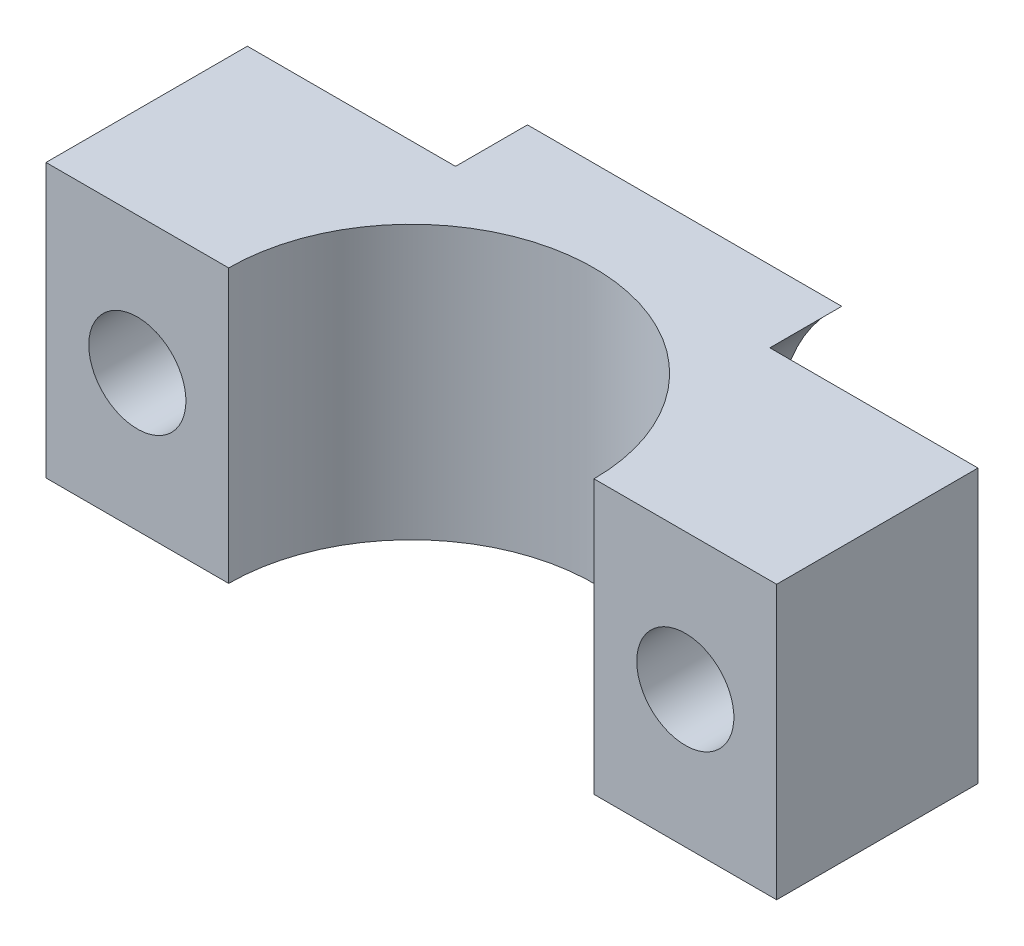
from build123d import *

# Parameters (mm, degrees)
BOSS_EXTRUDE1_DEPTH                           = 19
CBORE_FOR_M12_HEX_HEAD_CAP_SCREW2_D           = 6.75
CBORE_FOR_M12_HEX_HEAD_CAP_SCREW2_CBORE_D     = 25
CBORE_FOR_M12_HEX_HEAD_CAP_SCREW2_CBORE_DEPTH = 5


with BuildPart() as part:
    # Sketch1 → Boss-Extrude1 (new body)
    with BuildSketch(Plane(origin=(0, 0, 0), x_dir=(1, 0, 0), z_dir=(0, 1, 0))):
        with BuildLine():
            Line((12.7, 0), (25.4, 0))
            Line((25.4, 0), (25.4, 19))
            Line((25.4, 19), (-25.4, 19))
            Line((-25.4, 19), (-25.4, 0))
            Line((-25.4, 0), (-12.7, 0))
            ThreePointArc((-12.7, 0), (0, 12.7), (12.7, 0))
        make_face()
    extrude(amount=BOSS_EXTRUDE1_DEPTH)

    # CBORE for M12 Hex Head Cap Screw2 (through all)
    with Locations(Plane(origin=(19.05, 9.5, -19), x_dir=(-1, 0, 0), z_dir=(0, 0, -1))):
        with Locations((0, 0), (38.1, 0)):
            CounterBoreHole(CBORE_FOR_M12_HEX_HEAD_CAP_SCREW2_D / 2, CBORE_FOR_M12_HEX_HEAD_CAP_SCREW2_CBORE_D / 2, CBORE_FOR_M12_HEX_HEAD_CAP_SCREW2_CBORE_DEPTH)


solid = part.part
